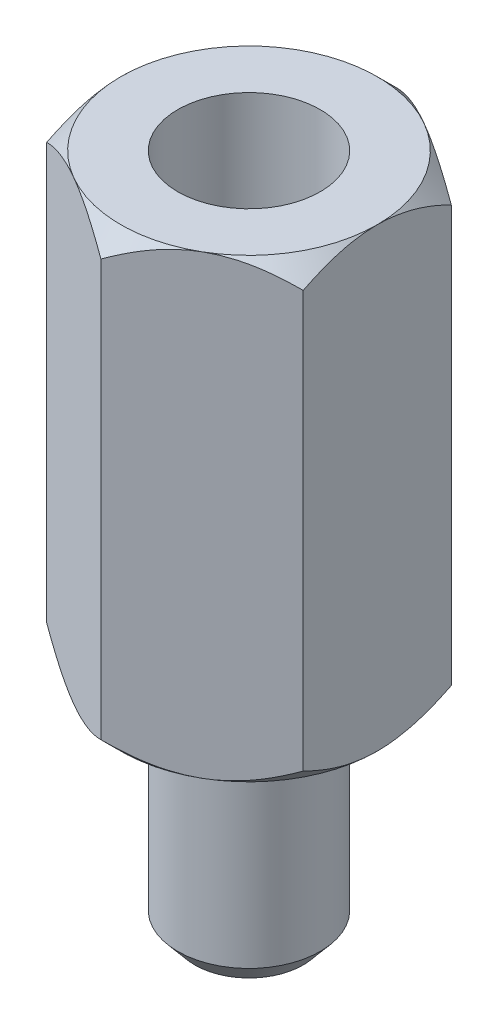
from build123d import *

# Parameters (mm, degrees)
SKETCH1_R           = 1.25
BOSS_EXTRUDE1_DEPTH = 3.9
BOSS_EXTRUDE2_DEPTH = 8
SKETCH3_R           = 1.25
CUT_EXTRUDE1_DEPTH  = 4.8
SKETCH4_OUTSIDE_W   = 18.848
SKETCH4_OUTSIDE_H   = 19.544
SKETCH4_OUTSIDE_R   = 2.25
CUT_EXTRUDE2_DEPTH  = 4.8
CUT_EXTRUDE2_TAPER  = 45
SKETCH5_OUTSIDE_W   = 27.248
SKETCH5_OUTSIDE_H   = 27.944
SKETCH5_OUTSIDE_R   = 2.25
CUT_EXTRUDE3_DEPTH  = 9
CUT_EXTRUDE3_TAPER  = 45
CHAMFER1_SIZE       = 0.3
CHAMFER1_SIZE2      = 0.357526078


with BuildPart() as part:
    # Sketch1 → Boss-Extrude1 (new body)
    with BuildSketch(Plane(origin=(0, 0, 0), x_dir=(1, 0, 0), z_dir=(0, 1, 0))):
        Circle(SKETCH1_R)
    extrude(amount=BOSS_EXTRUDE1_DEPTH)

    # Sketch2 → Boss-Extrude2 (add)
    with BuildSketch(Plane(origin=(0, 3.9, 0), x_dir=(1, 0, 0), z_dir=(0, 1, 0))):
        Polygon((0, 2.598076211), (-2.25, 1.299038106), (-2.25, -1.299038106), (0, -2.598076211), (2.25, -1.299038106), (2.25, 1.299038106), align=None)
    extrude(amount=BOSS_EXTRUDE2_DEPTH)

    # Sketch3 → Cut-Extrude1 (cut)
    with BuildSketch(Plane(origin=(0, 11.9, 0), x_dir=(1, 0, 0), z_dir=(0, 1, 0))):
        Circle(SKETCH3_R)
    extrude(amount=-CUT_EXTRUDE1_DEPTH, mode=Mode.SUBTRACT)

    # Sketch4 outside → Cut-Extrude2 (cut)
    with BuildSketch(Plane(origin=(0, 11.9, 0), x_dir=(1, 0, 0), z_dir=(0, 1, 0))):
        Rectangle(SKETCH4_OUTSIDE_W, SKETCH4_OUTSIDE_H)
        Circle(SKETCH4_OUTSIDE_R, mode=Mode.SUBTRACT)
    extrude(amount=-CUT_EXTRUDE2_DEPTH, taper=CUT_EXTRUDE2_TAPER, mode=Mode.SUBTRACT)

    # Sketch5 outside → Cut-Extrude3 (cut, through all)
    with BuildSketch(Plane.XZ.offset(-3.9)):
        Rectangle(SKETCH5_OUTSIDE_W, SKETCH5_OUTSIDE_H)
        Circle(SKETCH5_OUTSIDE_R, mode=Mode.SUBTRACT)
    extrude(amount=-CUT_EXTRUDE3_DEPTH, taper=CUT_EXTRUDE3_TAPER, mode=Mode.SUBTRACT)

    # Chamfer1
    chamfer1_edges = [part.edges().sort_by_distance(p)[0] for p in [
        (-1.25, 0, 0),
    ]]
    chamfer1_side = [part.faces().sort_by_distance(p)[0] for p in [
        (0, 0, 0),
    ]]
    chamfer(chamfer1_edges, length=CHAMFER1_SIZE, length2=CHAMFER1_SIZE2, reference=chamfer1_side[0])


solid = part.part
